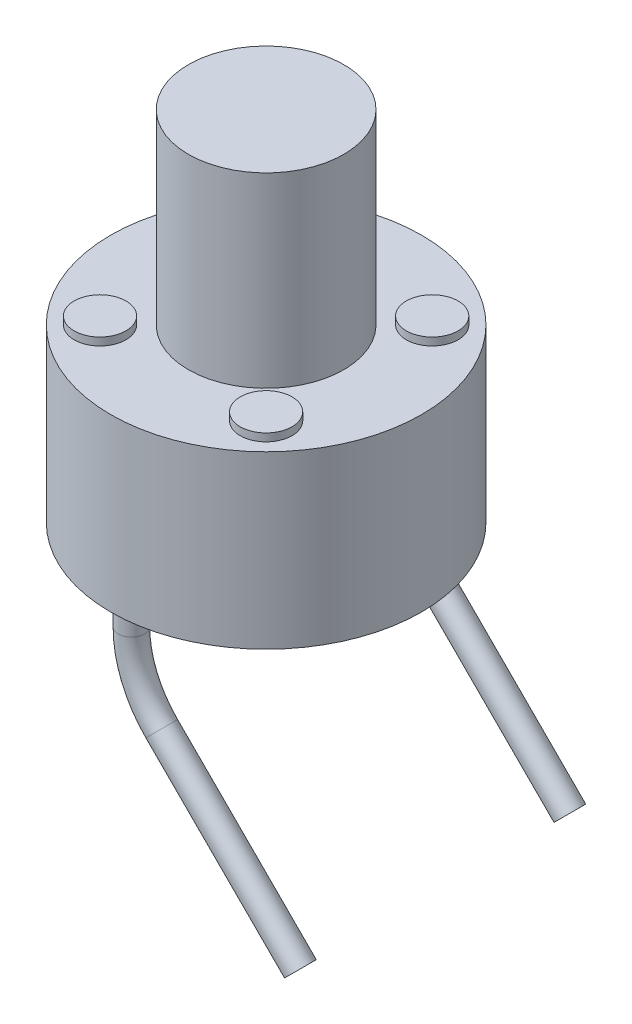
from build123d import *

# Parameters (mm, degrees)
SKETCH1_R           = 3
BOSS_EXTRUDE1_DEPTH = 3.3
SKETCH2_R           = 1.5
BOSS_EXTRUDE2_DEPTH = 3.6
SKETCH4_R           = 0.5
BOSS_EXTRUDE4_DEPTH = 0.15
SKETCH3_R           = 0.25


with BuildPart() as part:
    # Sketch1 → Boss-Extrude1 (new body)
    with BuildSketch(Plane(origin=(0, 0, 0), x_dir=(1, 0, 0), z_dir=(0, 1, 0))):
        Circle(SKETCH1_R)
    extrude(amount=BOSS_EXTRUDE1_DEPTH)

    # Sketch2 → Boss-Extrude2 (add)
    with BuildSketch(Plane(origin=(0, 3.3, 0), x_dir=(1, 0, 0), z_dir=(0, 1, 0))):
        Circle(SKETCH2_R)
    extrude(amount=BOSS_EXTRUDE2_DEPTH)

    # Sketch4 → Boss-Extrude4 (add)
    with BuildSketch(Plane(origin=(0, 3.3, 0), x_dir=(1, 0, 0), z_dir=(0, 1, 0))):
        with Locations((-1.60267659, 1.60267659)):
            Circle(SKETCH4_R)
        with Locations((1.60267659, 1.60267659)):
            Circle(SKETCH4_R)
        with Locations((-1.60267659, -1.60267659)):
            Circle(SKETCH4_R)
        with Locations((1.60267659, -1.60267659)):
            Circle(SKETCH4_R)
    extrude(amount=BOSS_EXTRUDE4_DEPTH)

    # Sweep2: sweep along a path in Sketch5
    with BuildLine(Plane.XY) as sweep2_path:
        Line((0, 0), (0, -0.442064994))
        ThreePointArc((0, -0.442064994), (0.152240935, -1.207431859), (0.585786438, -1.856278556))
        Line((0.585786438, -1.856278556), (3.261520237, -4.532012355))
    # Sketch3 → Sweep2 (sweep)
    with BuildSketch(Plane.XZ):
        with Locations((0, 2.6)):
            Circle(SKETCH3_R)
        with Locations((0, -2.6)):
            Circle(SKETCH3_R)
    sweep(path=sweep2_path.line)


solid = part.part
